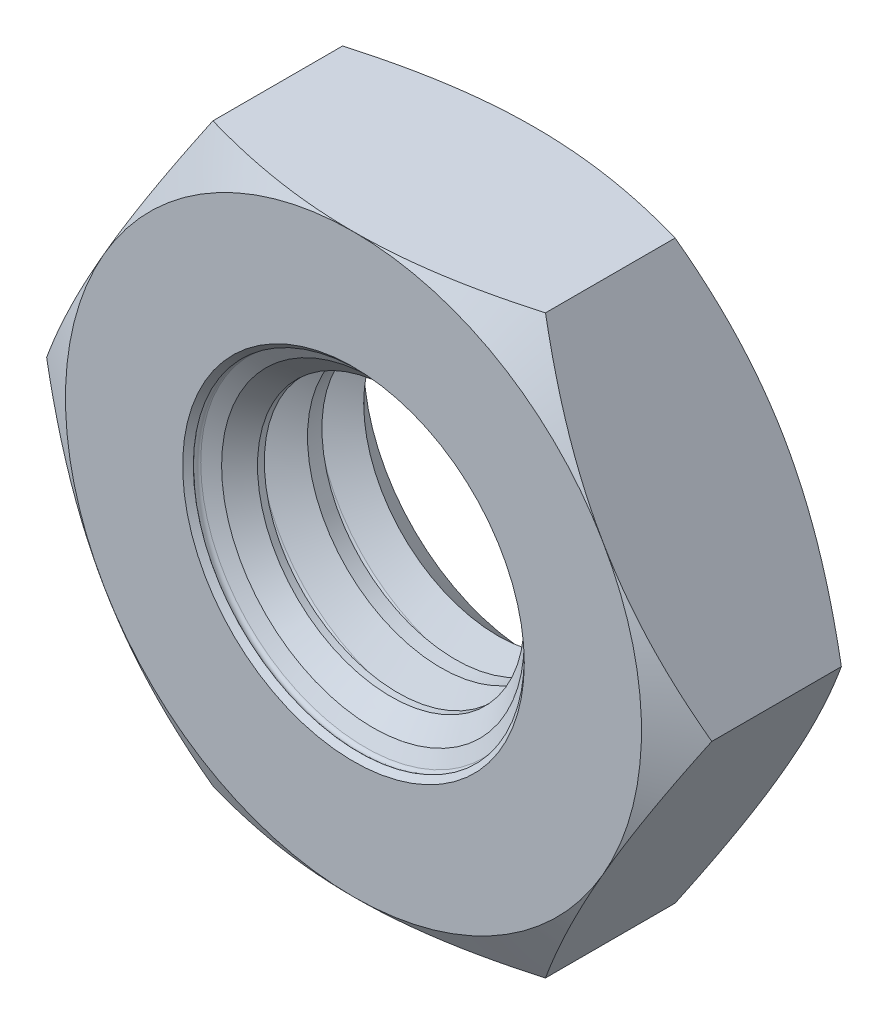
from build123d import *

# Parameters (mm, degrees)
SKETCH5_W               = 2.2
SKETCH5_H               = 7
SKETCH7_W               = 2.2
SKETCH7_H               = 2
SKETCH9_W               = 2.2
SKETCH9_H               = 0.454663337
THREAD_SIMPLE_COUNT     = 4
THREAD_SIMPLE_PITCH     = 0.7
SKETCH22_OUTSIDE_W      = 15.9
SKETCH22_OUTSIDE_H      = 15.9
CUT_PROFILE_OUTER_DEPTH = 3.2


with BuildPart() as part:
    # Sketch5 → body (revolve)
    with BuildSketch(Plane(origin=(0, 0, 0), x_dir=(0, 0, -1), z_dir=(1, 0, 0))):
        with Locations((1.1, 3.5)):
            Rectangle(SKETCH5_W, SKETCH5_H)
    revolve(axis=Axis((0, 0, 0), (0, 0, -1)))

    # Sketch19 → cut-chamfer-start (revolve, cut)
    with BuildSketch(Plane(origin=(0, 0, 0), x_dir=(0, 0, -1), z_dir=(1, 0, 0))):
        Polygon((2.020725942, -7), (0, -7), (0, -3.5), align=None)
    revolve(axis=Axis((0, 0, 0), (0, 0, -1)), mode=Mode.SUBTRACT)

    # Sketch20 → cut-chamfer-end (revolve, cut)
    with BuildSketch(Plane(origin=(0, 0, 0), x_dir=(0, 0, -1), z_dir=(1, 0, 0))):
        Polygon((2.2, -7), (0.179274058, -7), (2.2, -3.5), align=None)
    revolve(axis=Axis((0, 0, 0), (0, 0, -1)), mode=Mode.SUBTRACT)

    # Sketch7 → body-bore (revolve, cut)
    with BuildSketch(Plane(origin=(0, 0, 0), x_dir=(0, 0, -1), z_dir=(1, 0, 0))):
        with Locations((1.1, 1)):
            Rectangle(SKETCH7_W, SKETCH7_H)
    revolve(axis=Axis((0, 0, -2.2), (0, 0, 1)), mode=Mode.SUBTRACT)

    # Sketch9 → body-thread (revolve)
    with BuildSketch(Plane(origin=(0, 0, 0), x_dir=(0, 0, -1), z_dir=(1, 0, 0))):
        with Locations((1.1, -1.848445555)):
            Rectangle(SKETCH9_W, SKETCH9_H)
    revolve(axis=Axis((0, 0, 0), (0, 0, -1)))

    # Sketch10 → thread-single (revolve, cut)
    with BuildSketch(Plane(origin=(0, 0, 0), x_dir=(0, 0, -1), z_dir=(1, 0, 0))):
        with BuildLine():
            Line((2.15625, -2), (1.9375, -1.621113886))
            Line((1.9375, -1.621113886), (2.4625, -1.621113886))
            Line((2.4625, -1.621113886), (2.24375, -2))
            ThreePointArc((2.24375, -2), (2.2, -2.025259074), (2.15625, -2))
        make_face()
    thread_single = revolve(axis=Axis((0, 0, 0), (0, 0, -1)), mode=Mode.SUBTRACT)

    # thread-simple: thread-single ×4
    with Locations(*[(0, 0, i * THREAD_SIMPLE_PITCH) for i in range(1, THREAD_SIMPLE_COUNT)]):
        add(thread_single, mode=Mode.SUBTRACT)

    # Sketch15 → cut-chamfer-start-inner (revolve, cut)
    with BuildSketch(Plane(origin=(0, 0, 0), x_dir=(0, 0, -1), z_dir=(1, 0, 0))):
        Polygon((0, -1.621113886), (0.454663337, -1.621113886), (0, -2.075777223), align=None)
    revolve(axis=Axis((0, 0, 0), (0, 0, -1)), mode=Mode.SUBTRACT)

    # Sketch16 → cut-chamfer-end-inner (revolve, cut)
    with BuildSketch(Plane(origin=(0, 0, 0), x_dir=(0, 0, -1), z_dir=(1, 0, 0))):
        Polygon((2.2, -1.621113886), (2.2, -2.075777223), (1.745336663, -1.621113886), align=None)
    revolve(axis=Axis((0, 0, 0), (0, 0, -1)), mode=Mode.SUBTRACT)

    # Sketch22 outside → cut-profile-outer (cut, through all)
    with BuildSketch(Plane.XY):
        Rectangle(SKETCH22_OUTSIDE_W, SKETCH22_OUTSIDE_H)
        Polygon((4.041451884, 0), (2.020725942, 3.5), (-2.020725942, 3.5), (-4.041451884, 0), (-2.020725942, -3.5), (2.020725942, -3.5), align=None, mode=Mode.SUBTRACT)
    extrude(amount=-CUT_PROFILE_OUTER_DEPTH, mode=Mode.SUBTRACT)


solid = part.part
